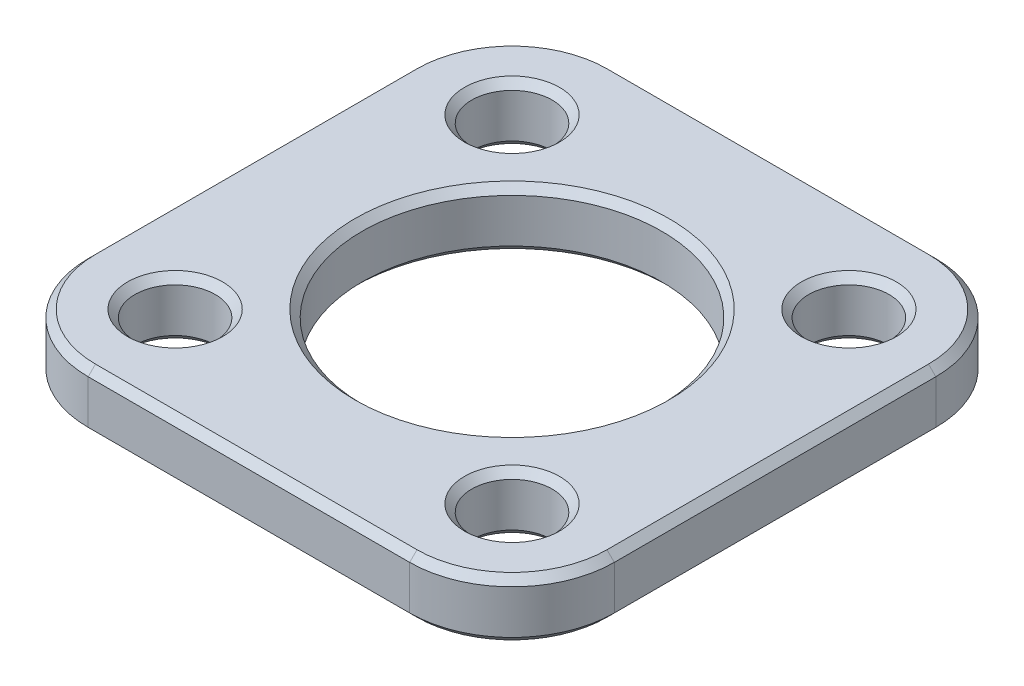
from build123d import *

# Parameters (mm, degrees)
SKETCH1_R           = 10.25
SKETCH1_R_2         = 2.75
BOSS_EXTRUDE1_DEPTH = 4
CHAMFER1_SIZE       = 0.5


with BuildPart() as part:
    # Sketch1 → Boss-Extrude1 (new body)
    with BuildSketch(Plane(origin=(0, 0, 0), x_dir=(1, 0, 0), z_dir=(0, 1, 0))):
        with BuildLine():
            Line((-11, 18), (11, 18))
            ThreePointArc((11, 18), (15.949747468, 15.949747468), (18, 11))
            Line((18, 11), (18, -11))
            ThreePointArc((18, -11), (15.949747468, -15.949747468), (11, -18))
            Line((11, -18), (-11, -18))
            ThreePointArc((-11, -18), (-15.949747468, -15.949747468), (-18, -11))
            Line((-18, -11), (-18, 11))
            ThreePointArc((-18, 11), (-15.949747468, 15.949747468), (-11, 18))
        make_face()
        Circle(SKETCH1_R, mode=Mode.SUBTRACT)
        with Locations((-11.525840533, 11.525840533)):
            Circle(SKETCH1_R_2, mode=Mode.SUBTRACT)
        with Locations((11.525840533, 11.525840533)):
            Circle(SKETCH1_R_2, mode=Mode.SUBTRACT)
        with Locations((11.525840533, -11.525840533)):
            Circle(SKETCH1_R_2, mode=Mode.SUBTRACT)
        with Locations((-11.525840533, -11.525840533)):
            Circle(SKETCH1_R_2, mode=Mode.SUBTRACT)
    extrude(amount=BOSS_EXTRUDE1_DEPTH)

    # Chamfer1
    chamfer1_edges = [part.edges().sort_by_distance(p)[0] for p in [
        (18, 0, 0),
        (15.949747468, 0, 15.949747468),
        (0, 0, 18),
        (-15.949747468, 0, 15.949747468),
        (15.949747468, 4, 15.949747468),
        (18, 4, 0),
        (15.949747468, 4, -15.949747468),
        (-10.25, 0, 0),
        (-10.25, 4, 0),
        (0, 4, -18),
        (-14.275840533, 0, -11.525840533),
        (-14.275840533, 4, -11.525840533),
        (-15.949747468, 4, -15.949747468),
        (8.775840533, 0, -11.525840533),
        (8.775840533, 4, -11.525840533),
        (-18, 4, 0),
        (8.775840533, 0, 11.525840533),
        (8.775840533, 4, 11.525840533),
        (-14.275840533, 0, 11.525840533),
        (-14.275840533, 4, 11.525840533),
        (-15.949747468, 4, 15.949747468),
        (-18, 0, 0),
        (0, 4, 18),
        (-15.949747468, 0, -15.949747468),
        (0, 0, -18),
        (15.949747468, 0, -15.949747468),
    ]]
    chamfer(chamfer1_edges, length=CHAMFER1_SIZE)


solid = part.part
